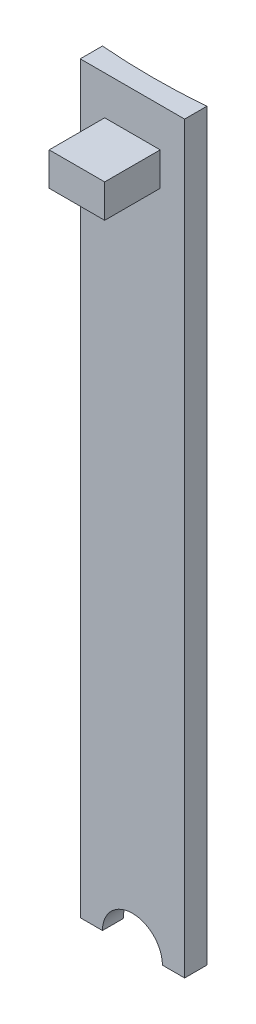
from build123d import *

# Parameters (mm, degrees)
BOSS_EXTRUDE1_DEPTH     = 1
CUT_EXTRUDE2_DEPTH      = 35.5
CUT_EXTRUDE2_DEPTH_BACK = 33.5
SKETCH3_W               = 5
SKETCH3_H               = 3
BOSS_EXTRUDE2_DEPTH     = 5


with BuildPart() as part:
    # Sketch1 → Boss-Extrude1 (new body, symmetric)
    with BuildSketch(Plane.XY):
        with BuildLine():
            Line((-2.7, 32.5), (-2.7, -32.5))
            ThreePointArc((-2.7, -32.5), (0, -29.8), (2.7, -32.5))
            Line((2.7, -32.5), (2.7, 32.5))
            Line((2.7, 32.5), (-2.7, 32.5))
        make_face()
        Polygon((4.7, -32.5), (2.7, -32.5), (2.7, 32.5), (-2.7, 32.5), (-2.7, -32.5), (-4.7, -32.5), (-4.7, 34.5), (4.7, 34.5), align=None)
    extrude(amount=BOSS_EXTRUDE1_DEPTH, both=True)

    # Sketch2 → Cut-Extrude2 (cut, two sides)
    with BuildSketch(Plane(origin=(0, 0, 0), x_dir=(1, 0, 0), z_dir=(0, 1, 0))) as cut_extrude2_sk:
        with BuildLine():
            ThreePointArc((-4.7, 1), (0, 0.805897581), (4.7, 1))
            Line((4.7, 1), (-4.7, 1))
        make_face()
        with BuildLine():
            Line((-4.7, 1), (4.7, 1))
            ThreePointArc((4.7, 1), (41.93387652, 19.198255851), (57, 57.805897581))
            ThreePointArc((57, 57.805897581), (-38.607641731, 99.739774101), (-4.7, 1))
        make_face()
    extrude(amount=CUT_EXTRUDE2_DEPTH, mode=Mode.SUBTRACT)
    extrude(cut_extrude2_sk.sketch, amount=-CUT_EXTRUDE2_DEPTH_BACK, mode=Mode.SUBTRACT)

    # Sketch3 → Boss-Extrude2 (add)
    with BuildSketch(Plane.XY.offset(1)):
        with Locations((0, 29.5)):
            Rectangle(SKETCH3_W, SKETCH3_H)
    extrude(amount=BOSS_EXTRUDE2_DEPTH)


solid = part.part
